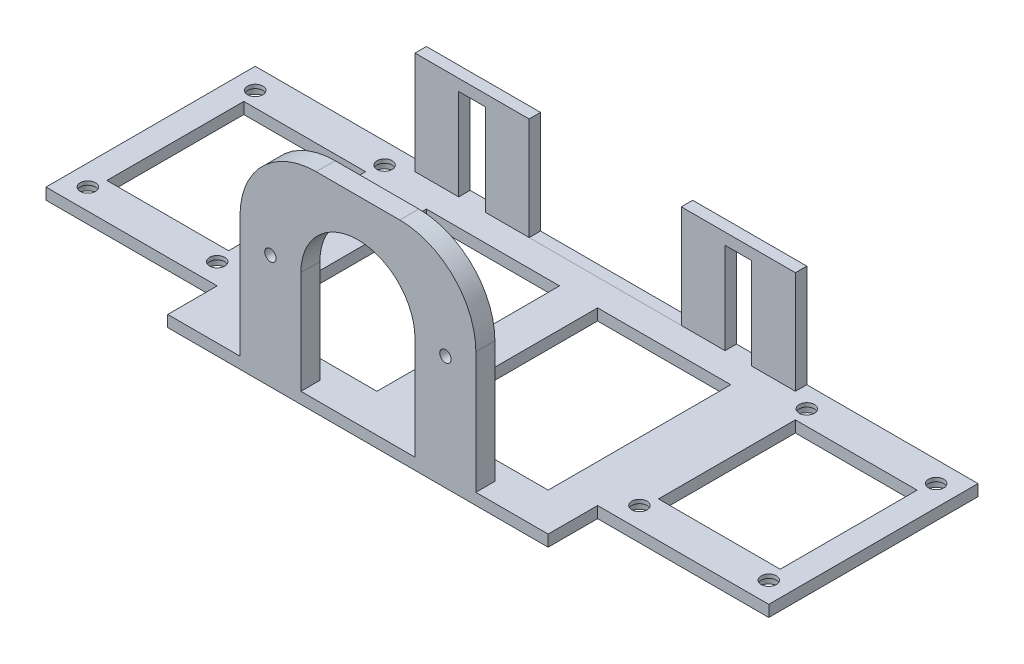
from build123d import *

# Parameters (mm, degrees)
SKETCH_1_W          = 100
SKETCH_1_H          = 68
EXTRUDE_1_DEPTH     = 3
SKETCH_2_W          = 100
SKETCH_2_H          = 3
EXTRUDE_2_DEPTH     = 27
SKETCH_3_W          = 7
SKETCH_3_H          = 24
CUT_EXTRUDE_2_DEPTH = 27
SKETCH_4_W          = 62
SKETCH_4_H          = 5
EXTRUDE_3_DEPTH     = 52
SKETCH_5_R          = 1.5
CUT_EXTRUDE_4_DEPTH = 5
SKETCH_7_W          = 35
SKETCH_7_H          = 48
CUT_EXTRUDE_5_DEPTH = 3
SKETCH_8_W          = 55
SKETCH_8_H          = 3
EXTRUDE_4_DEPTH     = 45
SKETCH_11_W         = 55
SKETCH_11_H         = 3
EXTRUDE_5_DEPTH     = 45
SKETCH_10_R         = 2
SKETCH_10_W         = 32
SKETCH_10_H         = 36
CUT_EXTRUDE_6_DEPTH = 45
SKETCH_12_R         = 3
CUT_EXTRUDE_7_DEPTH = 2
SKETCH_13_W         = 40
SKETCH_13_H         = 27.004423226
CUT_EXTRUDE_8_DEPTH = 3
FILLET_1_R          = 20


with BuildPart() as part:
    # 스케치1 → 보스-돌출1 (new body)
    with BuildSketch(Plane(origin=(0, 0, 0), x_dir=(1, 0, 0), z_dir=(0, 1, 0))):
        Rectangle(SKETCH_1_W, SKETCH_1_H)
    extrude(amount=EXTRUDE_1_DEPTH)

    # 스케치2 → 보스-돌출2 (add)
    with BuildSketch(Plane(origin=(0, 3, 0), x_dir=(1, 0, 0), z_dir=(0, 1, 0))):
        with Locations((0, 32.5)):
            Rectangle(SKETCH_2_W, SKETCH_2_H)
    extrude(amount=EXTRUDE_2_DEPTH)

    # 스케치3 → 컷-돌출2 (cut)
    with BuildSketch(Plane.XY.offset(-31)):
        with Locations((-35, 15)):
            Rectangle(SKETCH_3_W, SKETCH_3_H)
        with Locations((35, 15)):
            Rectangle(SKETCH_3_W, SKETCH_3_H)
    extrude(amount=-CUT_EXTRUDE_2_DEPTH, mode=Mode.SUBTRACT)

    # 스케치4 → 보스-돌출3 (add)
    with BuildSketch(Plane(origin=(0, 3, 0), x_dir=(1, 0, 0), z_dir=(0, 1, 0))):
        with Locations((0, -31.5)):
            Rectangle(SKETCH_4_W, SKETCH_4_H)
    extrude(amount=EXTRUDE_3_DEPTH)

    # 스케치5 → 컷-돌출4 (cut)
    with BuildSketch(Plane.XY.offset(34)):
        with Locations((-23, 30)):
            Circle(SKETCH_5_R)
        with Locations((23, 30)):
            Circle(SKETCH_5_R)
        with BuildLine():
            Line((-15, 30), (-15, 3))
            Line((-15, 3), (15, 3))
            Line((15, 3), (15, 30))
            ThreePointArc((15, 30), (0, 45), (-15, 30))
        make_face()
    extrude(amount=-CUT_EXTRUDE_4_DEPTH, mode=Mode.SUBTRACT)

    # 스케치7 → 컷-돌출5 (cut)
    with BuildSketch(Plane.XZ):
        with Locations((22.5, 0)):
            Rectangle(SKETCH_7_W, SKETCH_7_H)
        with Locations((-22.5, 0)):
            Rectangle(SKETCH_7_W, SKETCH_7_H)
    extrude(amount=-CUT_EXTRUDE_5_DEPTH, mode=Mode.SUBTRACT)

    # 스케치8 → 보스-돌출4 (add)
    with BuildSketch(Plane(origin=(50, 0, 0), x_dir=(0, 0, -1), z_dir=(1, 0, 0))):
        with Locations((6.5, 1.5)):
            Rectangle(SKETCH_8_W, SKETCH_8_H)
    extrude(amount=EXTRUDE_4_DEPTH)

    # 스케치11 → 보스-돌출5 (add)
    with BuildSketch(Plane.ZY.offset(50)):
        with Locations((-6.5, 1.5)):
            Rectangle(SKETCH_11_W, SKETCH_11_H)
    extrude(amount=EXTRUDE_5_DEPTH)

    # 스케치10 → 컷-돌출6 (cut)
    with BuildSketch(Plane(origin=(0, 3, 0), x_dir=(1, 0, 0), z_dir=(0, 1, 0))):
        with Locations((55.5, -15.5)):
            Circle(SKETCH_10_R)
        with Locations((55.5, 28.5)):
            Circle(SKETCH_10_R)
        with Locations((89.5, 28.5)):
            Circle(SKETCH_10_R)
        with Locations((89.5, -15.5)):
            Circle(SKETCH_10_R)
        with Locations((-89.5, -15.5)):
            Circle(SKETCH_10_R)
        with Locations((-55.5, -15.5)):
            Circle(SKETCH_10_R)
        with Locations((-55.5, 28.5)):
            Circle(SKETCH_10_R)
        with Locations((-89.5, 28.5)):
            Circle(SKETCH_10_R)
        with Locations((72.5, 6.5)):
            Rectangle(SKETCH_10_W, SKETCH_10_H)
        with Locations((-72.5, 6.5)):
            Rectangle(SKETCH_10_W, SKETCH_10_H)
    extrude(amount=-CUT_EXTRUDE_6_DEPTH, mode=Mode.SUBTRACT)

    # 스케치12 → 컷-돌출7 (cut)
    with BuildSketch(Plane.XZ):
        with Locations((89.5, -28.5)):
            Circle(SKETCH_12_R)
        with Locations((89.5, 15.5)):
            Circle(SKETCH_12_R)
        with Locations((55.5, 15.5)):
            Circle(SKETCH_12_R)
        with Locations((55.5, -28.5)):
            Circle(SKETCH_12_R)
        with Locations((-89.5, 15.5)):
            Circle(SKETCH_12_R)
        with Locations((-55.5, 15.5)):
            Circle(SKETCH_12_R)
        with Locations((-55.5, -28.5)):
            Circle(SKETCH_12_R)
        with Locations((-89.5, -28.5)):
            Circle(SKETCH_12_R)
    extrude(amount=-CUT_EXTRUDE_7_DEPTH, mode=Mode.SUBTRACT)

    # 스케치13 → 컷-돌출8 (cut)
    with BuildSketch(Plane(origin=(0, 0, -34), x_dir=(-1, 0, 0), z_dir=(0, 0, -1))):
        with Locations((0, 16.497788387)):
            Rectangle(SKETCH_13_W, SKETCH_13_H)
    extrude(amount=-CUT_EXTRUDE_8_DEPTH, mode=Mode.SUBTRACT)

    # 필렛1
    fillet_1_edges = [part.edges().sort_by_distance(p)[0] for p in [
        (31, 55, 31.5),
        (-31, 55, 31.5),
    ]]
    fillet(fillet_1_edges, radius=FILLET_1_R)


solid = part.part
